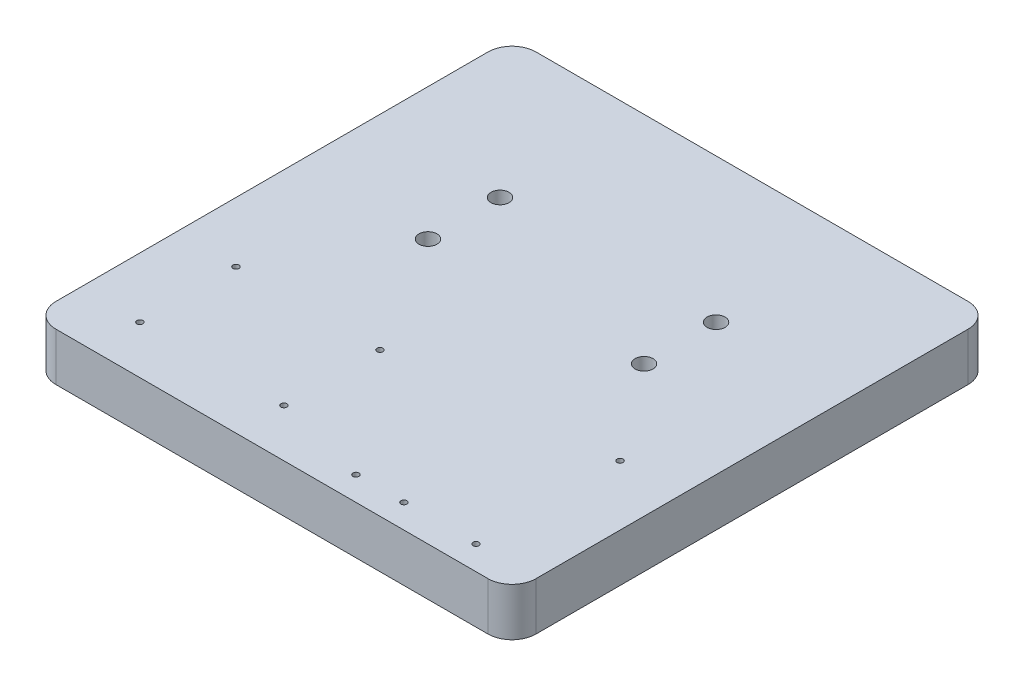
from build123d import *

# Parameters (mm, degrees)
CROQUIS1_W              = 200
CROQUIS1_H              = 200
SALIENTE_EXTRUIR1_DEPTH = 20
REDONDEO1_R             = 10
CROQUIS5_W              = 120
CROQUIS5_H              = 80
SALIENTE_EXTRUIR3_DEPTH = 20
CROQUIS3_R              = 3.75
CORTAR_EXTRUIR2_DEPTH   = 21
CROQUIS6_R              = 1.25
CORTAR_EXTRUIR3_DEPTH   = 21


with BuildPart() as part:
    # Croquis1 → Saliente-Extruir1 (new body)
    with BuildSketch(Plane(origin=(0, 0, 0), x_dir=(1, 0, 0), z_dir=(0, 1, 0))):
        Rectangle(CROQUIS1_W, CROQUIS1_H)
    extrude(amount=SALIENTE_EXTRUIR1_DEPTH)

    # Redondeo1
    redondeo1_edges = [part.edges().sort_by_distance(p)[0] for p in [
        (100, 10, 100),
        (-100, 10, 100),
        (-100, 10, -100),
        (100, 10, -100),
    ]]
    fillet(redondeo1_edges, radius=REDONDEO1_R)

    # Croquis5 → Saliente-Extruir3 (add)
    with BuildSketch(Plane(origin=(0, 20, 0), x_dir=(1, 0, 0), z_dir=(0, 1, 0))):
        with Locations((0, 20)):
            Rectangle(CROQUIS5_W, CROQUIS5_H)
    extrude(amount=-SALIENTE_EXTRUIR3_DEPTH)

    # Croquis3 → Cortar-Extruir2 (cut, through all)
    with BuildSketch(Plane(origin=(0, 20, 0), x_dir=(1, 0, 0), z_dir=(0, 1, 0))):
        with Locations((-45, 10)):
            Circle(CROQUIS3_R)
        with Locations((45, 10)):
            Circle(CROQUIS3_R)
    cortar_extruir2 = extrude(amount=-CORTAR_EXTRUIR2_DEPTH, mode=Mode.SUBTRACT)

    # Simetría3: Cortar-Extruir2 across plane
    add(cortar_extruir2.mirror(Plane.XY.offset(-25)), mode=Mode.SUBTRACT)

    # Croquis6 → Cortar-Extruir3 (cut, through all)
    with BuildSketch(Plane(origin=(0, 20, 0), x_dir=(1, 0, 0), z_dir=(0, 1, 0))):
        with Locations((75, -90)):
            Circle(CROQUIS6_R)
        with Locations((75, -30)):
            Circle(CROQUIS6_R)
        with Locations((45, -90)):
            Circle(CROQUIS6_R)
        with Locations((25, -90)):
            Circle(CROQUIS6_R)
        with Locations((-15, -80)):
            Circle(CROQUIS6_R)
        with Locations((-15, -40)):
            Circle(CROQUIS6_R)
        with Locations((-75, -40)):
            Circle(CROQUIS6_R)
        with Locations((-75, -80)):
            Circle(CROQUIS6_R)
    extrude(amount=-CORTAR_EXTRUIR3_DEPTH, mode=Mode.SUBTRACT)


solid = part.part
